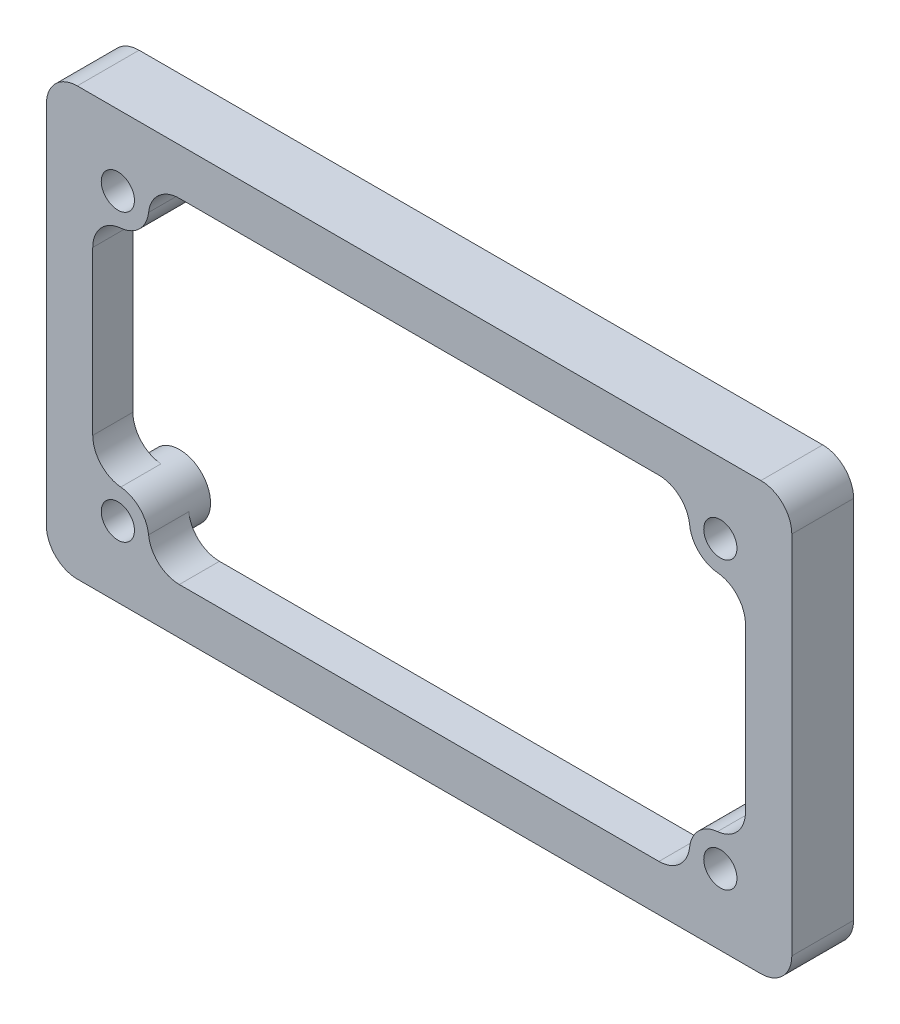
from build123d import *

# Parameters (mm, degrees)
SKETCH1_W           = 48.25
SKETCH1_H           = 27.65
SKETCH1_W_2         = 45.25
SKETCH1_H_2         = 24.65
MAIN_BODY_DEPTH     = 4
SKETCH3_W           = 45.25
SKETCH3_H           = 24.65
SKETCH3_W_2         = 42.25
SKETCH3_H_2         = 21.65
BOSS_EXTRUDE2_DEPTH = 2.6
BOSS_EXTRUDE3_START = -2.6
BOSS_EXTRUDE3_DEPTH = 4
SKETCH5_R           = 1.075
CUT_EXTRUDE1_DEPTH  = 1.4
SKETCH6_R           = 1.075
CUT_EXTRUDE2_DEPTH  = 3.6
FILLET1_R           = 2


with BuildPart() as part:
    # Sketch1 → Main Body (new body)
    with BuildSketch(Plane.XY):
        with Locations((22.625, 12.325)):
            Rectangle(SKETCH1_W, SKETCH1_H)
        with Locations((22.625, 12.325)):
            Rectangle(SKETCH1_W_2, SKETCH1_H_2, mode=Mode.SUBTRACT)
    extrude(amount=MAIN_BODY_DEPTH)

    # Sketch3 → Boss-Extrude2 (add)
    with BuildSketch(Plane.XY.offset(4)):
        with Locations((22.625, 12.325)):
            Rectangle(SKETCH3_W, SKETCH3_H)
        with Locations((22.625, 12.325)):
            Rectangle(SKETCH3_W_2, SKETCH3_H_2, mode=Mode.SUBTRACT)
    extrude(amount=-BOSS_EXTRUDE2_DEPTH)

    # Sketch4 → Boss-Extrude3 (add)
    with BuildSketch(Plane(origin=(0, 0, 1.4), x_dir=(-1, 0, 0), z_dir=(0, 0, -1)).offset(BOSS_EXTRUDE3_START)):
        with BuildLine():
            Line((-1.125, 21.575), (-1.125, 23.575))
            Line((-1.125, 23.575), (-3.125, 23.575))
            ThreePointArc((-3.125, 23.575), (-4.539213562, 20.160786438), (-1.125, 21.575))
        make_face()
        with BuildLine():
            Line((-1.125, 1.075), (-3.125, 1.075))
            ThreePointArc((-3.125, 1.075), (-4.539213562, 4.489213562), (-1.125, 3.075))
            Line((-1.125, 3.075), (-1.125, 1.075))
        make_face()
        with BuildLine():
            Line((-44.125, 3.075), (-44.125, 1.075))
            Line((-44.125, 1.075), (-42.125, 1.075))
            ThreePointArc((-42.125, 1.075), (-40.710786438, 4.489213562), (-44.125, 3.075))
        make_face()
        with BuildLine():
            Line((-44.125, 23.575), (-42.125, 23.575))
            ThreePointArc((-42.125, 23.575), (-40.710786438, 20.160786438), (-44.125, 21.575))
            Line((-44.125, 21.575), (-44.125, 23.575))
        make_face()
    extrude(amount=BOSS_EXTRUDE3_DEPTH)

    # Sketch5 → Cut-Extrude1 (cut)
    with BuildSketch(Plane(origin=(0, 0, 0), x_dir=(-1, 0, 0), z_dir=(0, 0, -1))):
        with BuildLine():
            ThreePointArc((-1.125, 21.575), (-1.710786438, 22.989213562), (-3.125, 23.575))
            Line((-3.125, 23.575), (-1.125, 23.575))
            Line((-1.125, 23.575), (-1.125, 21.575))
        make_face()
        with Locations((-3.125, 21.575)):
            Circle(SKETCH5_R)
        with Locations((-3.125, 3.075)):
            Circle(SKETCH5_R)
        with BuildLine():
            Line((-1.125, 1.075), (-1.125, 3.075))
            ThreePointArc((-1.125, 3.075), (-1.710786438, 1.660786438), (-3.125, 1.075))
            Line((-3.125, 1.075), (-1.125, 1.075))
        make_face()
        with Locations((-42.125, 3.075)):
            Circle(SKETCH5_R)
        with BuildLine():
            ThreePointArc((-44.125, 3.075), (-43.539213562, 1.660786438), (-42.125, 1.075))
            Line((-42.125, 1.075), (-44.125, 1.075))
            Line((-44.125, 1.075), (-44.125, 3.075))
        make_face()
        with Locations((-42.125, 21.575)):
            Circle(SKETCH5_R)
        with BuildLine():
            ThreePointArc((-42.125, 23.575), (-43.539213562, 22.989213562), (-44.125, 21.575))
            Line((-44.125, 21.575), (-44.125, 23.575))
            Line((-44.125, 23.575), (-42.125, 23.575))
        make_face()
    extrude(amount=-CUT_EXTRUDE1_DEPTH, mode=Mode.SUBTRACT)

    # Sketch6 → Cut-Extrude2 (cut, through all)
    with BuildSketch(Plane(origin=(0, 0, 1.4), x_dir=(-1, 0, 0), z_dir=(0, 0, -1))):
        with Locations((-3.125, 21.575)):
            Circle(SKETCH6_R)
        with Locations((-3.125, 3.075)):
            Circle(SKETCH6_R)
        with Locations((-42.125, 3.075)):
            Circle(SKETCH6_R)
        with Locations((-42.125, 21.575)):
            Circle(SKETCH6_R)
    extrude(amount=-CUT_EXTRUDE2_DEPTH, mode=Mode.SUBTRACT)

    # Fillet1
    fillet1_edges = [part.edges().sort_by_distance(p)[0] for p in [
        (43.75, 20.409077618, 2.7),
        (40.892370696, 23.15, 2.7),
        (45.25, 24.65, 0.7),
        (0, 24.65, 0.7),
        (45.25, 0, 0.7),
        (0, 0, 0.7),
        (4.357629304, 1.5, 2.7),
        (1.5, 4.240922382, 2.7),
        (43.75, 4.240922382, 2.7),
        (-1.5, 26.15, 2),
        (46.75, 26.15, 2),
        (40.892370696, 1.5, 2.7),
        (46.75, -1.5, 2),
        (-1.5, -1.5, 2),
        (4.357629304, 23.15, 2.7),
        (1.5, 20.409077618, 2.7),
    ]]
    fillet(fillet1_edges, radius=FILLET1_R)


solid = part.part
